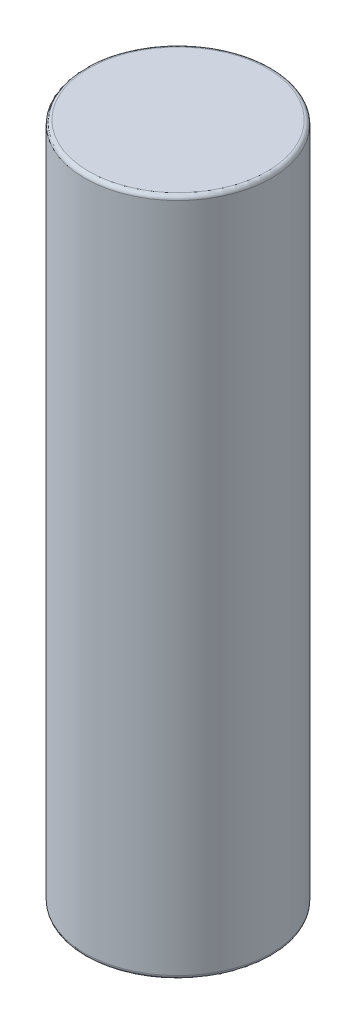
from build123d import *

# Parameters (mm, degrees)
SKETCH1_R           = 7
BOSS_EXTRUDE1_DEPTH = 51
FILLET1_R           = 0.3


with BuildPart() as part:
    # Sketch1 → Boss-Extrude1 (new body)
    with BuildSketch(Plane(origin=(0, 0, 0), x_dir=(1, 0, 0), z_dir=(0, 1, 0))):
        Circle(SKETCH1_R)
    extrude(amount=BOSS_EXTRUDE1_DEPTH)

    # Fillet1
    fillet1_edges = [part.edges().sort_by_distance(p)[0] for p in [
        (-7, 0, 0),
        (-7, 51, 0),
    ]]
    fillet(fillet1_edges, radius=FILLET1_R)


solid = part.part
